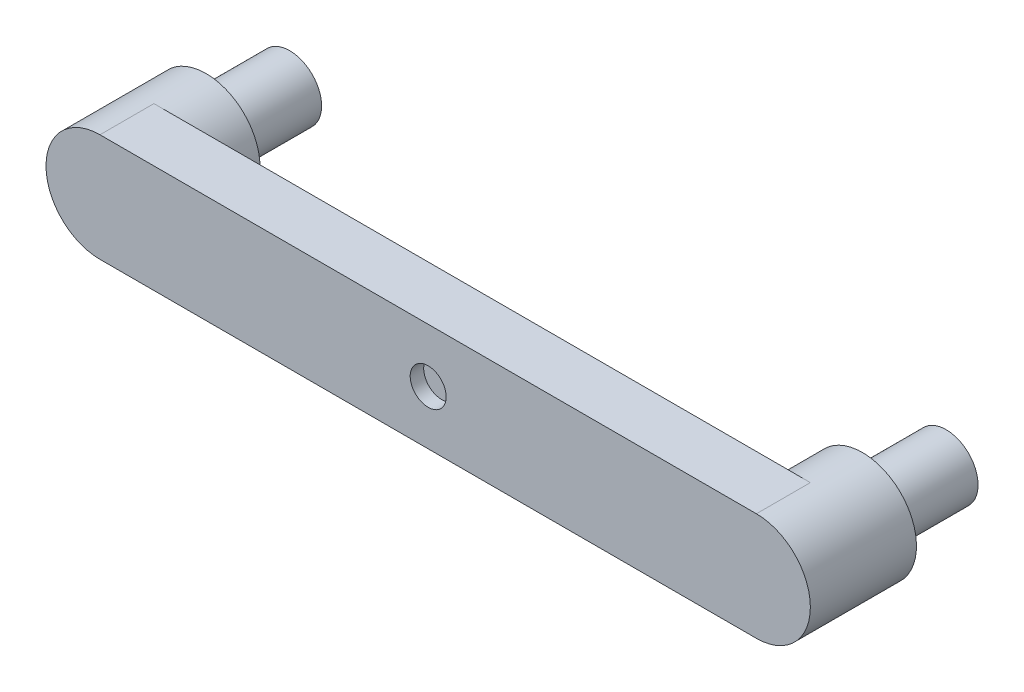
from build123d import *

# Parameters (mm, degrees)
BOSS_EXTRUDE1_DEPTH = 30
SKETCH2_R           = 30
BOSS_EXTRUDE2_DEPTH = 29
SKETCH1_3_R         = 10
CUT_EXTRUDE1_DEPTH  = 30
BOSS_EXTRUDE3_START = -59
SKETCH1_4_R         = 17.75
BOSS_EXTRUDE3_DEPTH = 46.5
SKETCH3_W           = 60
SKETCH3_H           = 15
CUT_EXTRUDE2_DEPTH  = 45


with BuildPart() as part:
    # Sketch1 → Boss-Extrude1 (new body)
    with BuildSketch(Plane.XY):
        with BuildLine():
            Line((-182.5, 30), (182.5, 30))
            ThreePointArc((182.5, 30), (212.5, 0), (182.5, -30))
            Line((182.5, -30), (-182.5, -30))
            ThreePointArc((-182.5, -30), (-212.5, 0), (-182.5, 30))
        make_face()
    extrude(amount=-BOSS_EXTRUDE1_DEPTH)

    # Sketch2 → Boss-Extrude2 (add)
    with BuildSketch(Plane(origin=(0, 0, -30), x_dir=(-1, 0, 0), z_dir=(0, 0, -1))):
        with Locations((-182.5, 0)):
            Circle(SKETCH2_R)
        with Locations((182.5, 0)):
            Circle(SKETCH2_R)
    extrude(amount=BOSS_EXTRUDE2_DEPTH)

    # Sketch1_3 → Cut-Extrude1 (cut)
    with BuildSketch(Plane.XY):
        Circle(SKETCH1_3_R)
    extrude(amount=-CUT_EXTRUDE1_DEPTH, mode=Mode.SUBTRACT)

    # Sketch1_4 → Boss-Extrude3 (add)
    with BuildSketch(Plane.XY.offset(BOSS_EXTRUDE3_START)):
        with Locations((182.5, 0)):
            Circle(SKETCH1_4_R)
        with Locations((-182.5, 0)):
            Circle(SKETCH1_4_R)
    extrude(amount=-BOSS_EXTRUDE3_DEPTH)

    # Sketch3 → Cut-Extrude2 (cut)
    with BuildSketch(Plane.XZ.offset(30)):
        with Locations((0, -15)):
            Rectangle(SKETCH3_W, SKETCH3_H)
    extrude(amount=-CUT_EXTRUDE2_DEPTH, mode=Mode.SUBTRACT)


solid = part.part
